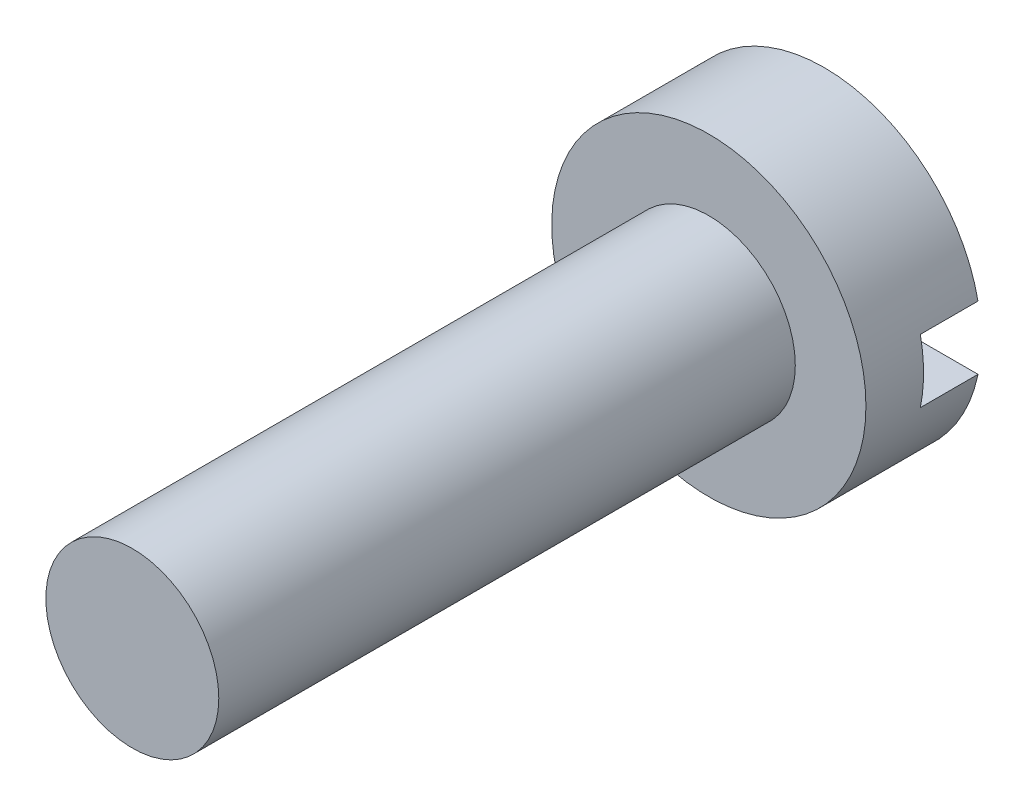
from build123d import *

# Parameters (mm, degrees)
SKETCH1_R          = 2.725
EXTRUDE1_DEPTH     = 2
CUT_EXTRUDE1_DEPTH = 1
SKETCH3_R          = 1.5
EXTRUDE2_DEPTH     = 10


with BuildPart() as part:
    # Sketch1 → Extrude1 (new body)
    with BuildSketch(Plane.XY):
        Circle(SKETCH1_R)
    extrude(amount=EXTRUDE1_DEPTH)

    # Sketch2 → Cut-Extrude1 (cut)
    with BuildSketch(Plane(origin=(0, 0, 0), x_dir=(-1, 0, 0), z_dir=(0, 0, -1))):
        Polygon((3.449801909, 0), (3.449801909, 0.55), (-3.901269584, 0.55), (-3.901269584, -0.55), (3.449801909, -0.55), align=None)
    extrude(amount=-CUT_EXTRUDE1_DEPTH, mode=Mode.SUBTRACT)

    # Sketch3 → Extrude2 (add)
    with BuildSketch(Plane.XY.offset(2)):
        Circle(SKETCH3_R)
    extrude(amount=EXTRUDE2_DEPTH)


solid = part.part
